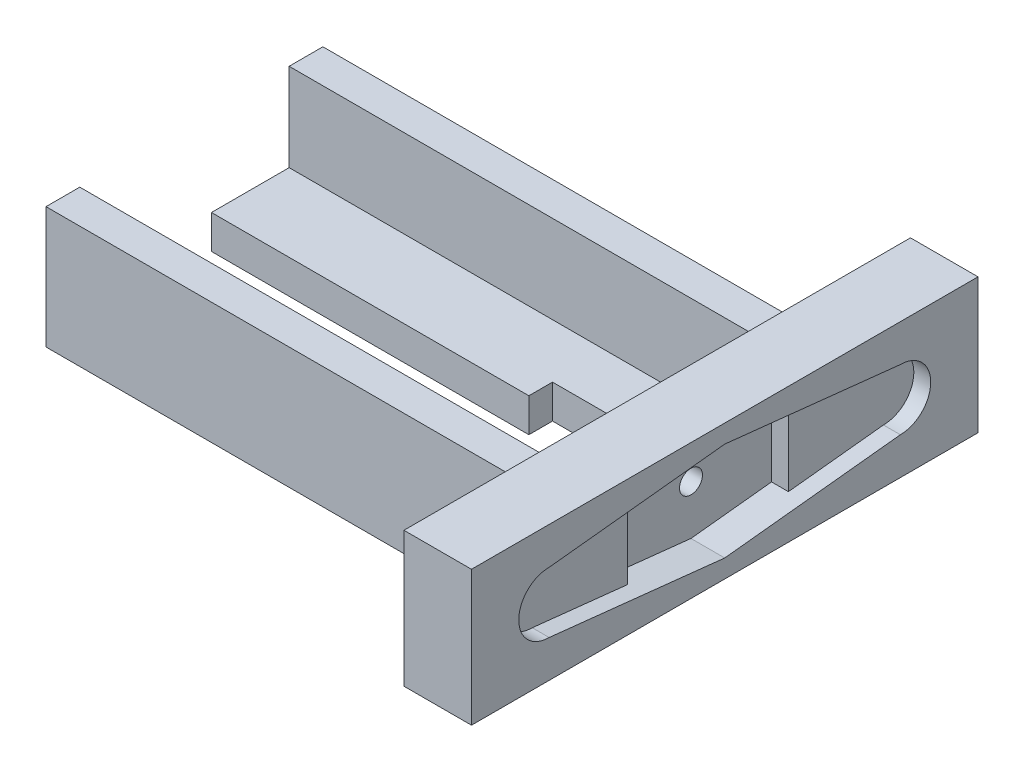
from build123d import *

# Parameters (mm, degrees)
SKETCH_1_W                   = 10
SKETCH_1_H                   = 75
EXTRUDE_2_DEPTH              = 20
SKETCH_10_W                  = 31
SKETCH_10_H                  = 5
EXTRUDE_3_DEPTH              = 70
SKETCH_11_W                  = 5
SKETCH_11_H                  = 18
EXTRUDE_4_DEPTH              = 70
SKETCH_12_W                  = 5
SKETCH_12_H                  = 18
EXTRUDE_5_DEPTH              = 70
SKETCH_13_W                  = 60
SKETCH_13_H                  = 8
CUT_EXTRUDE_6_DEPTH          = 20
SKETCH_14_W                  = 10
SKETCH_14_H                  = 3.5
CUT_EXTRUDE_7_DEPTH          = 20
HOLE_WIZARD_M3_1_D           = 3.4
HOLE_WIZARD_M3_1_DEPTH       = 20
HOLE_WIZARD_M3_1_CBORE_D     = 6.7
HOLE_WIZARD_M3_1_CBORE_DEPTH = 1.65
HOLE_WIZARD_M3_1_TIP         = 1.021463052
CUT_EXTRUDE_8_DEPTH          = 2.5
CUT_EXTRUDE_9_DEPTH          = 5


with BuildPart() as part:
    # 草图1 → 凸台-拉伸2 (new body)
    with BuildSketch(Plane(origin=(0, 0, 0), x_dir=(1, 0, 0), z_dir=(0, 1, 0))):
        with Locations((5, 37.5)):
            Rectangle(SKETCH_1_W, SKETCH_1_H)
    extrude(amount=EXTRUDE_2_DEPTH)

    # 草图10 → 凸台-拉伸3 (add)
    with BuildSketch(Plane.ZY):
        with Locations((-37.5, 2.5)):
            Rectangle(SKETCH_10_W, SKETCH_10_H)
    extrude(amount=EXTRUDE_3_DEPTH)

    # 草图11 → 凸台-拉伸4 (add)
    with BuildSketch(Plane.ZY):
        with Locations((-19.5, 9)):
            Rectangle(SKETCH_11_W, SKETCH_11_H)
    extrude(amount=EXTRUDE_4_DEPTH)

    # 草图12 → 凸台-拉伸5 (add)
    with BuildSketch(Plane.ZY):
        with Locations((-55.5, 9)):
            Rectangle(SKETCH_12_W, SKETCH_12_H)
    extrude(amount=EXTRUDE_5_DEPTH)

    # 草图13 → 切除-拉伸6 (cut)
    with BuildSketch(Plane(origin=(0, 5, 0), x_dir=(1, 0, 0), z_dir=(0, 1, 0))):
        with Locations((-40, 37.5)):
            Rectangle(SKETCH_13_W, SKETCH_13_H)
    extrude(amount=-CUT_EXTRUDE_6_DEPTH, mode=Mode.SUBTRACT)

    # 草图14 → 切除-拉伸7 (cut)
    with BuildSketch(Plane(origin=(0, 5, 0), x_dir=(1, 0, 0), z_dir=(0, 1, 0))):
        with Locations((-18, 43.25)):
            Rectangle(SKETCH_14_W, SKETCH_14_H)
    extrude(amount=-CUT_EXTRUDE_7_DEPTH, mode=Mode.SUBTRACT)

    # M3 凹圆头螺钉的柱形沉头孔1
    with Locations(Plane(origin=(0, 10, -37.5), x_dir=(0, 0, -1), z_dir=(-1, 0, 0))):
        with Locations((0, 0)):
            CounterBoreHole(HOLE_WIZARD_M3_1_D / 2, HOLE_WIZARD_M3_1_CBORE_D / 2, HOLE_WIZARD_M3_1_CBORE_DEPTH, depth=HOLE_WIZARD_M3_1_DEPTH)
            with Locations((0, 0, -(HOLE_WIZARD_M3_1_DEPTH + HOLE_WIZARD_M3_1_TIP / 2))):  # 118° drill point
                Cone(0, HOLE_WIZARD_M3_1_D / 2, HOLE_WIZARD_M3_1_TIP, mode=Mode.SUBTRACT)

    # 草图5 → 切除-拉伸8 (cut)
    with BuildSketch(Plane(origin=(10, 0, 0), x_dir=(0, 0, -1), z_dir=(1, 0, 0))):
        with BuildLine():
            Line((63.5, 14.5), (39.054281703, 17.132615817))
            ThreePointArc((39.054281703, 17.132615817), (43.184903536, 14.579505626), (44.8, 10))
            ThreePointArc((44.8, 10), (43.184903536, 5.420494374), (39.054281703, 2.867384183))
            Line((39.054281703, 2.867384183), (63.5, 5.5))
            ThreePointArc((63.5, 5.5), (68, 10), (63.5, 14.5))
        make_face()
        with BuildLine():
            Line((37.5, 17.3), (35.945718297, 17.132615817))
            ThreePointArc((35.945718297, 17.132615817), (30.2, 10), (35.945718297, 2.867384183))
            Line((35.945718297, 2.867384183), (37.5, 2.7))
            Line((37.5, 2.7), (39.054281703, 2.867384183))
            ThreePointArc((39.054281703, 2.867384183), (43.184903536, 5.420494374), (44.8, 10))
            ThreePointArc((44.8, 10), (43.184903536, 14.579505626), (39.054281703, 17.132615817))
            Line((39.054281703, 17.132615817), (37.5, 17.3))
        make_face()
        with BuildLine():
            Line((35.945718297, 17.132615817), (11.5, 14.5))
            ThreePointArc((11.5, 14.5), (7, 10), (11.5, 5.5))
            Line((11.5, 5.5), (35.945718297, 2.867384183))
            ThreePointArc((35.945718297, 2.867384183), (30.2, 10), (35.945718297, 17.132615817))
        make_face()
    extrude(amount=-CUT_EXTRUDE_8_DEPTH, mode=Mode.SUBTRACT)

    # 草图16 → 切除-拉伸9 (cut)
    with BuildSketch(Plane(origin=(10, 0, 0), x_dir=(0, 0, -1), z_dir=(1, 0, 0))):
        Polygon((37.5, 17.3), (25.568986317, 16.015121603), (25.568986317, 3.984878397), (37.5, 2.7), (49.431013683, 3.984878397), (49.431013683, 16.015121603), align=None)
    extrude(amount=-CUT_EXTRUDE_9_DEPTH, mode=Mode.SUBTRACT)


solid = part.part
